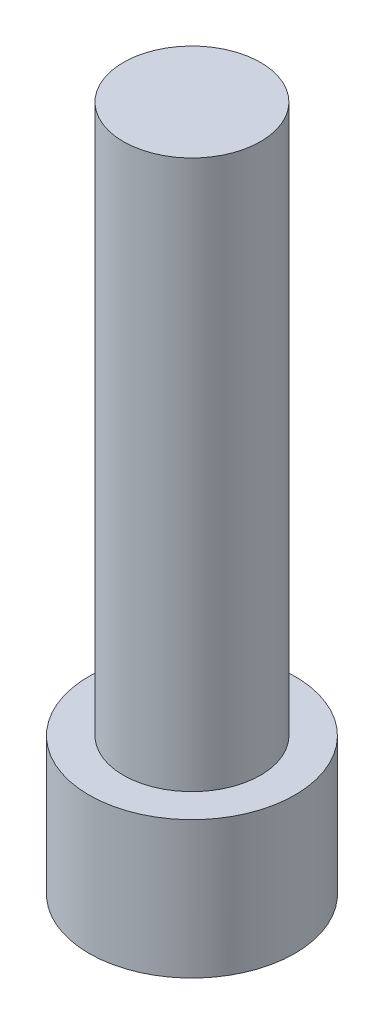
from build123d import *

# Parameters (mm, degrees)
BOSS_EXTRUDE1_DEPTH = 40
SKETCH1_3_R         = 7.5
BOSS_EXTRUDE2_DEPTH = 3
SKETCH2_R           = 7.5
BOSS_EXTRUDE3_DEPTH = 7


with BuildPart() as part:
    # Sketch1 → Boss-Extrude1 (new body)
    with BuildSketch(Plane(origin=(0, 0, 0), x_dir=(1, 0, 0), z_dir=(0, 1, 0))):
        with BuildLine():
            ThreePointArc((5, 0), (4.829629138, 1.294095202), (4.330127043, 2.499999958))
            ThreePointArc((4.330127043, 2.499999958), (2.500000021, 4.330127007), (0, 5))
            ThreePointArc((0, 5), (-2.499999995, 4.330127022), (-4.330127013, 2.500000011))
            ThreePointArc((-4.330127013, 2.500000011), (-5, 0), (-4.330127013, -2.500000011))
            ThreePointArc((-4.330127013, -2.500000011), (-2.499999995, -4.330127022), (0, -5))
            ThreePointArc((0, -5), (2.499999979, -4.330127031), (4.330126994, -2.500000043))
            ThreePointArc((4.330126994, -2.500000043), (4.829629125, -1.294095249), (5, 0))
        make_face()
    extrude(amount=BOSS_EXTRUDE1_DEPTH)

    # Sketch1_3 → Boss-Extrude2 (add)
    with BuildSketch(Plane(origin=(0, 0, 0), x_dir=(1, 0, 0), z_dir=(0, 1, 0))):
        Circle(SKETCH1_3_R)
    extrude(amount=-BOSS_EXTRUDE2_DEPTH)

    # Sketch2 → Boss-Extrude3 (add)
    with BuildSketch(Plane.XZ.offset(3)):
        Circle(SKETCH2_R)
        Polygon((5.773502692, 0), (2.886751346, 5), (-2.886751346, 5), (-5.773502692, 0), (-2.886751346, -5), (2.886751346, -5), align=None, mode=Mode.SUBTRACT)
    extrude(amount=BOSS_EXTRUDE3_DEPTH)


solid = part.part
